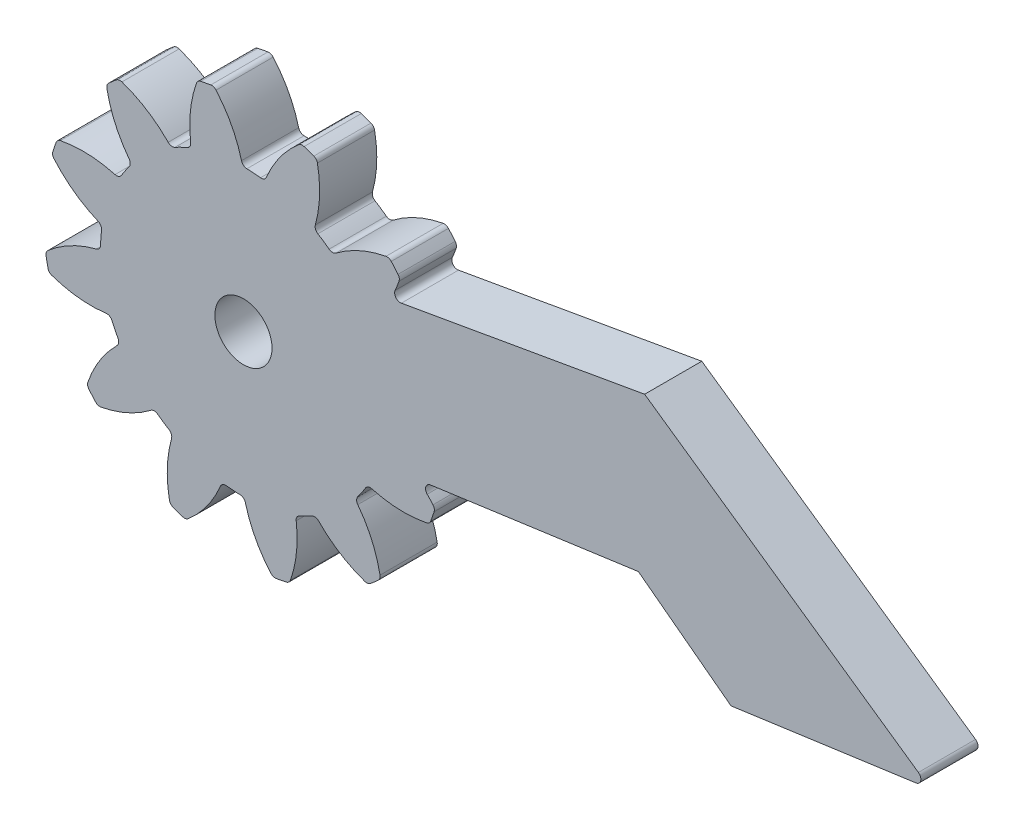
from build123d import *

# Parameters (mm, degrees)
ESQUISSE20_R        = 1.5
BOSS_EXTRU_18_DEPTH = 3


with BuildPart() as part:
    # Esquisse20 → Boss.-Extru.18 (new body)
    with BuildSketch(Plane.XY):
        with BuildLine():
            Line((110.974145272, 39.836071078), (121.886788051, 41.354939341))
            Line((121.886788051, 41.354939341), (126.749523122, 37.68045145))
            Line((126.749523122, 37.68045145), (136.453547574, 39.031099049))
            ThreePointArc((136.453547574, 39.031099049), (136.70394605, 39.25838517), (136.583626314, 39.574425576))
            Line((136.583626314, 39.574425576), (122.215724565, 49.579536305))
            Line((122.215724565, 49.579536305), (109.446142116, 47.334623838))
            ThreePointArc((109.446142116, 47.334623838), (109.157676293, 47.445546281), (109.120229419, 47.752326416))
            ThreePointArc((109.120229419, 47.752326416), (109.228042095, 48.009211598), (109.32429992, 48.270646104))
            ThreePointArc((109.32429992, 48.270646104), (109.335764075, 48.421294196), (109.272350858, 48.558425661))
            ThreePointArc((109.272350858, 48.558425661), (109.097464559, 48.765803687), (108.917279288, 48.968594544))
            ThreePointArc((108.917279288, 48.968594544), (108.79064668, 49.050998774), (108.639910127, 49.061234313))
            ThreePointArc((108.639910127, 49.061234313), (107.261509219, 48.631031321), (106.01862318, 47.895981682))
            ThreePointArc((106.01862318, 47.895981682), (105.838096498, 47.834835241), (105.657168579, 47.894784036))
            ThreePointArc((105.657168579, 47.894784036), (105.512617586, 48.000463717), (105.365584876, 48.10266238))
            ThreePointArc((105.365584876, 48.10266238), (105.21615426, 48.20132177), (105.064410914, 48.296385651))
            ThreePointArc((105.064410914, 48.296385651), (104.94165105, 48.44218958), (104.931503697, 48.632520348))
            ThreePointArc((104.931503697, 48.632520348), (105.15332497, 50.059355658), (105.041782665, 51.499016031))
            ThreePointArc((105.041782665, 51.499016031), (104.976386869, 51.635213184), (104.85290368, 51.722265908))
            ThreePointArc((104.85290368, 51.722265908), (104.597758689, 51.814417397), (104.340318239, 51.899946795))
            ThreePointArc((104.340318239, 51.899946795), (104.189449068, 51.907994647), (104.053789615, 51.841490608))
            ThreePointArc((104.053789615, 51.841490608), (103.075160908, 50.779723434), (102.366314843, 49.521708754))
            ThreePointArc((102.366314843, 49.521708754), (102.240547371, 49.378491042), (102.053884799, 49.339944262))
            ThreePointArc((102.053884799, 49.339944262), (101.875860127, 49.359190054), (101.697426734, 49.374180337))
            ThreePointArc((101.697426734, 49.374180337), (101.518686329, 49.384906567), (101.339740796, 49.39136263))
            ThreePointArc((101.339740796, 49.39136263), (101.160525671, 49.456252605), (101.056572421, 49.616010208))
            ThreePointArc((101.056572421, 49.616010208), (100.535257624, 50.96259647), (99.718828968, 52.153607774))
            ThreePointArc((99.718828968, 52.153607774), (99.59409597, 52.23886007), (99.44363003, 52.252508346))
            ThreePointArc((99.44363003, 52.252508346), (99.176592242, 52.204741381), (98.910877573, 52.150091787))
            ThreePointArc((98.910877573, 52.150091787), (98.776197112, 52.081626847), (98.691964599, 51.956202932))
            ThreePointArc((98.691964599, 51.956202932), (98.375330865, 50.547371233), (98.390459505, 49.10347553))
            ThreePointArc((98.390459505, 49.10347553), (98.353150535, 48.916561617), (98.210769396, 48.78984784))
            ThreePointArc((98.210769396, 48.78984784), (98.046972612, 48.717502849), (97.884949619, 48.641268118))
            ThreePointArc((97.884949619, 48.641268118), (97.724792772, 48.561187104), (97.566593363, 48.477305452))
            ThreePointArc((97.566593363, 48.477305452), (97.378943525, 48.443894256), (97.209038568, 48.530271774))
            ThreePointArc((97.209038568, 48.530271774), (96.08427358, 49.435792287), (94.781719971, 50.059024004))
            ThreePointArc((94.781719971, 50.059024004), (94.631071878, 50.070488159), (94.493940414, 50.007074943))
            ThreePointArc((94.493940414, 50.007074943), (94.286562388, 49.832188643), (94.083771531, 49.652003372))
            ThreePointArc((94.083771531, 49.652003372), (94.001367301, 49.525370764), (93.991131762, 49.374634211))
            ThreePointArc((93.991131762, 49.374634211), (94.421334754, 47.996233303), (95.156384393, 46.753347264))
            ThreePointArc((95.156384393, 46.753347264), (95.217530833, 46.572820582), (95.157582038, 46.391892663))
            ThreePointArc((95.157582038, 46.391892663), (95.051902358, 46.24734167), (94.949703695, 46.100308961))
            ThreePointArc((94.949703695, 46.100308961), (94.851044305, 45.950878344), (94.755980424, 45.799134999))
            ThreePointArc((94.755980424, 45.799134999), (94.610176495, 45.676375134), (94.419845727, 45.666227781))
            ThreePointArc((94.419845727, 45.666227781), (92.993010417, 45.888049055), (91.553350043, 45.77650675))
            ThreePointArc((91.553350043, 45.77650675), (91.417152891, 45.711110954), (91.330100167, 45.587627765))
            ThreePointArc((91.330100167, 45.587627765), (91.237948678, 45.332482774), (91.15241928, 45.075042323))
            ThreePointArc((91.15241928, 45.075042323), (91.144371427, 44.924173153), (91.210875467, 44.788513699))
            ThreePointArc((91.210875467, 44.788513699), (92.272642641, 43.809884992), (93.530657321, 43.101038928))
            ThreePointArc((93.530657321, 43.101038928), (93.673875032, 42.975271455), (93.712421813, 42.788608884))
            ThreePointArc((93.712421813, 42.788608884), (93.693176021, 42.610584211), (93.678185738, 42.432150818))
            ThreePointArc((93.678185738, 42.432150818), (93.667459507, 42.253410413), (93.661003444, 42.07446488))
            ThreePointArc((93.661003444, 42.07446488), (93.59611347, 41.895249755), (93.436355867, 41.791296505))
            ThreePointArc((93.436355867, 41.791296505), (92.089769605, 41.269981709), (90.8987583, 40.453553052))
            ThreePointArc((90.8987583, 40.453553052), (90.813506004, 40.328820055), (90.799857729, 40.178354115))
            ThreePointArc((90.799857729, 40.178354115), (90.847624694, 39.911316326), (90.902274287, 39.645601657))
            ThreePointArc((90.902274287, 39.645601657), (90.970739228, 39.510921196), (91.096163143, 39.426688683))
            ThreePointArc((91.096163143, 39.426688683), (92.504994842, 39.110054949), (93.948890545, 39.12518359))
            ThreePointArc((93.948890545, 39.12518359), (94.135804458, 39.08787462), (94.262518234, 38.945493481))
            ThreePointArc((94.262518234, 38.945493481), (94.334863226, 38.781696696), (94.411097956, 38.619673703))
            ThreePointArc((94.411097956, 38.619673703), (94.491178971, 38.459516856), (94.575060623, 38.301317448))
            ThreePointArc((94.575060623, 38.301317448), (94.608471819, 38.113667609), (94.522094301, 37.943762652))
            ThreePointArc((94.522094301, 37.943762652), (93.616573788, 36.818997664), (92.993342071, 35.516444055))
            ThreePointArc((92.993342071, 35.516444055), (92.981877915, 35.365795963), (93.045291132, 35.228664498))
            ThreePointArc((93.045291132, 35.228664498), (93.220177431, 35.021286472), (93.400362702, 34.818495616))
            ThreePointArc((93.400362702, 34.818495616), (93.526995311, 34.736091385), (93.677731863, 34.725855847))
            ThreePointArc((93.677731863, 34.725855847), (95.056132772, 35.156058839), (96.299018811, 35.891108478))
            ThreePointArc((96.299018811, 35.891108478), (96.479545492, 35.952254918), (96.660473412, 35.892306123))
            ThreePointArc((96.660473412, 35.892306123), (96.805024404, 35.786626442), (96.952057114, 35.684427779))
            ThreePointArc((96.952057114, 35.684427779), (97.101487731, 35.585768389), (97.253231076, 35.490704508))
            ThreePointArc((97.253231076, 35.490704508), (97.37599094, 35.344900579), (97.386138294, 35.154569811))
            ThreePointArc((97.386138294, 35.154569811), (97.16431702, 33.727734502), (97.275859325, 32.288074128))
            ThreePointArc((97.275859325, 32.288074128), (97.341255121, 32.151876975), (97.46473831, 32.064824252))
            ThreePointArc((97.46473831, 32.064824252), (97.719883301, 31.972672762), (97.977323751, 31.887143364))
            ThreePointArc((97.977323751, 31.887143364), (98.128192922, 31.879095512), (98.263852376, 31.945599551))
            ThreePointArc((98.263852376, 31.945599551), (99.242481083, 33.007366725), (99.951327147, 34.265381405))
            ThreePointArc((99.951327147, 34.265381405), (100.077094619, 34.408599117), (100.263757191, 34.447145897))
            ThreePointArc((100.263757191, 34.447145897), (100.441781863, 34.427900105), (100.620215257, 34.412909822))
            ThreePointArc((100.620215257, 34.412909822), (100.798955662, 34.402183592), (100.977901194, 34.395727529))
            ThreePointArc((100.977901194, 34.395727529), (101.15711632, 34.330837554), (101.26106957, 34.171079951))
            ThreePointArc((101.26106957, 34.171079951), (101.782384366, 32.824493689), (102.598813023, 31.633482385))
            ThreePointArc((102.598813023, 31.633482385), (102.72354602, 31.548230089), (102.87401196, 31.534581813))
            ThreePointArc((102.87401196, 31.534581813), (103.141049749, 31.582348778), (103.406764418, 31.636998372))
            ThreePointArc((103.406764418, 31.636998372), (103.541444878, 31.705463312), (103.625677392, 31.830887227))
            ThreePointArc((103.625677392, 31.830887227), (103.942311126, 33.239718926), (103.927182485, 34.683614629))
            ThreePointArc((103.927182485, 34.683614629), (103.964491455, 34.870528542), (104.106872594, 34.997242319))
            ThreePointArc((104.106872594, 34.997242319), (104.270669379, 35.06958731), (104.432692372, 35.145822041))
            ThreePointArc((104.432692372, 35.145822041), (104.592849218, 35.225903055), (104.751048627, 35.309784707))
            ThreePointArc((104.751048627, 35.309784707), (104.938698466, 35.343195904), (105.108603422, 35.256818386))
            ThreePointArc((105.108603422, 35.256818386), (106.233368411, 34.351297873), (107.53592202, 33.728066155))
            ThreePointArc((107.53592202, 33.728066155), (107.686570112, 33.716602), (107.823701576, 33.780015217))
            ThreePointArc((107.823701576, 33.780015217), (108.031079603, 33.954901516), (108.233870459, 34.135086787))
            ThreePointArc((108.233870459, 34.135086787), (108.316274689, 34.261719395), (108.326510228, 34.412455948))
            ThreePointArc((108.326510228, 34.412455948), (107.896307236, 35.790856856), (107.161257597, 37.033742895))
            ThreePointArc((107.161257597, 37.033742895), (107.100111157, 37.214269577), (107.160059952, 37.395197496))
            ThreePointArc((107.160059952, 37.395197496), (107.265739633, 37.539748489), (107.367938296, 37.686781199))
            ThreePointArc((107.367938296, 37.686781199), (107.466597686, 37.836211815), (107.561661567, 37.987955161))
            ThreePointArc((107.561661567, 37.987955161), (107.707465496, 38.110715025), (107.897796264, 38.120862378))
            ThreePointArc((107.897796264, 38.120862378), (109.324631573, 37.899041104), (110.764291947, 38.010583409))
            ThreePointArc((110.764291947, 38.010583409), (110.9004891, 38.075979206), (110.987541823, 38.199462394))
            ThreePointArc((110.987541823, 38.199462394), (111.079693313, 38.454607385), (111.165222711, 38.712047836))
            ThreePointArc((111.165222711, 38.712047836), (111.173270563, 38.862917007), (111.106766523, 38.99857646))
            ThreePointArc((111.106766523, 38.99857646), (110.95766042, 39.16577253), (110.802658091, 39.327517495))
            ThreePointArc((110.802658091, 39.327517495), (110.731228871, 39.634793859), (110.974145272, 39.836071078))
        make_face()
        with Locations((101.158820995, 41.89354508)):
            Circle(ESQUISSE20_R, mode=Mode.SUBTRACT)
    extrude(amount=BOSS_EXTRU_18_DEPTH)


solid = part.part
